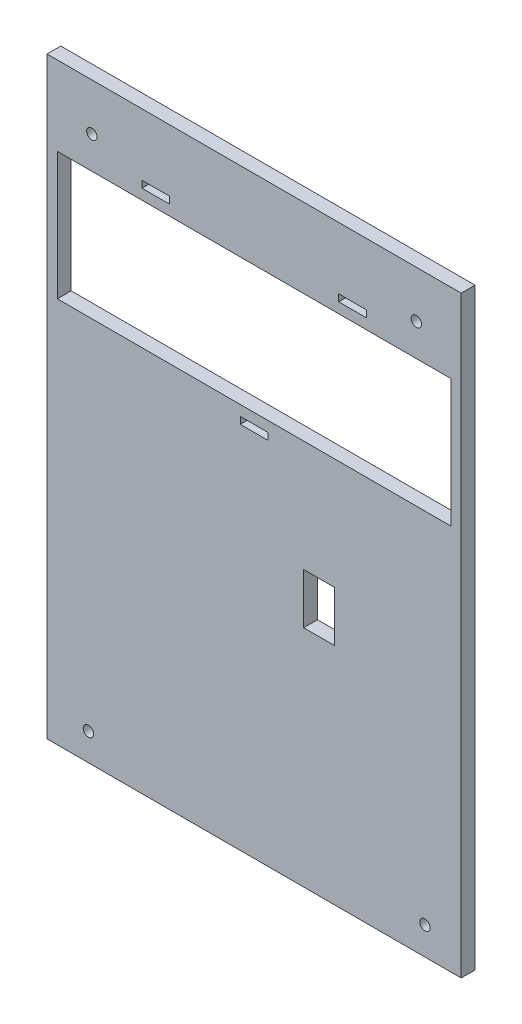
from build123d import *

# Parameters (mm, degrees)
SKETCH1_W           = 120
SKETCH1_H           = 171.827864376
SKETCH1_R           = 1.5
SKETCH1_W_2         = 114
SKETCH1_H_2         = 37
BOSS_EXTRUDE1_DEPTH = 4
SKETCH2_W           = 9
SKETCH2_H           = 14.6
CUT_EXTRUDE1_DEPTH  = 5


with BuildPart() as part:
    # Sketch1 → Boss-Extrude1 (new body)
    with BuildSketch(Plane.XY):
        with Locations((60, 77.985)):
            Rectangle(SKETCH1_W, SKETCH1_H)
        with Locations((13, 150.313145751)):
            Circle(SKETCH1_R, mode=Mode.SUBTRACT)
        with Locations((107, 150.313145751)):
            Circle(SKETCH1_R, mode=Mode.SUBTRACT)
        with Locations((109.5, 0.156854249)):
            Circle(SKETCH1_R, mode=Mode.SUBTRACT)
        with Locations((12, 0)):
            Circle(SKETCH1_R, mode=Mode.SUBTRACT)
        with Locations((60, 122.47)):
            Rectangle(SKETCH1_W_2, SKETCH1_H_2, mode=Mode.SUBTRACT)
        Polygon((31.5, 143.97), (27.5, 143.97), (27.5, 145.97), (35.5, 145.97), (35.5, 143.97), align=None, mode=Mode.SUBTRACT)
        Polygon((92.5, 145.97), (84.5, 145.97), (84.5, 143.97), (88.5, 143.97), (92.5, 143.97), align=None, mode=Mode.SUBTRACT)
        Polygon((60, 98.97), (56, 98.97), (56, 100.97), (64, 100.97), (64, 98.97), align=None, mode=Mode.SUBTRACT)
    extrude(amount=BOSS_EXTRUDE1_DEPTH)

    # Sketch2 → Cut-Extrude1 (cut, through all)
    with BuildSketch(Plane(origin=(0, 0, 0), x_dir=(-1, 0, 0), z_dir=(0, 0, -1))):
        with Locations((-78.856585714, 64.426127197)):
            Rectangle(SKETCH2_W, SKETCH2_H)
    extrude(amount=-CUT_EXTRUDE1_DEPTH, mode=Mode.SUBTRACT)


solid = part.part
